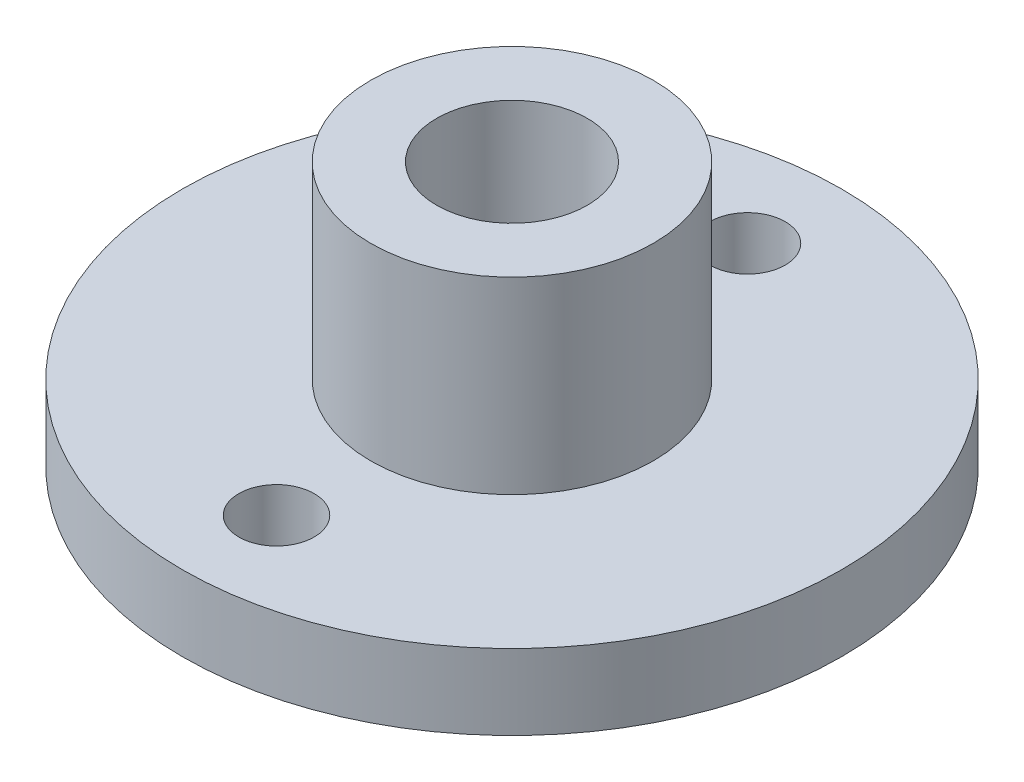
from build123d import *

# Parameters (mm, degrees)
SKETCH1_R           = 17.5
SKETCH1_R_2         = 2
BOSS_EXTRUDE1_DEPTH = 4
SKETCH2_R           = 7.5
SKETCH2_R_2         = 4
BOSS_EXTRUDE2_DEPTH = 10


with BuildPart() as part:
    # Sketch1 → Boss-Extrude1 (new body)
    with BuildSketch(Plane(origin=(0, 0, 0), x_dir=(1, 0, 0), z_dir=(0, 1, 0))):
        Circle(SKETCH1_R)
        with Locations((0, 12.5)):
            Circle(SKETCH1_R_2, mode=Mode.SUBTRACT)
        with Locations((0, -12.5)):
            Circle(SKETCH1_R_2, mode=Mode.SUBTRACT)
    extrude(amount=BOSS_EXTRUDE1_DEPTH)

    # Sketch2 → Boss-Extrude2 (add)
    with BuildSketch(Plane(origin=(0, 4, 0), x_dir=(1, 0, 0), z_dir=(0, 1, 0))):
        Circle(SKETCH2_R)
        Circle(SKETCH2_R_2, mode=Mode.SUBTRACT)
    extrude(amount=BOSS_EXTRUDE2_DEPTH)


solid = part.part
